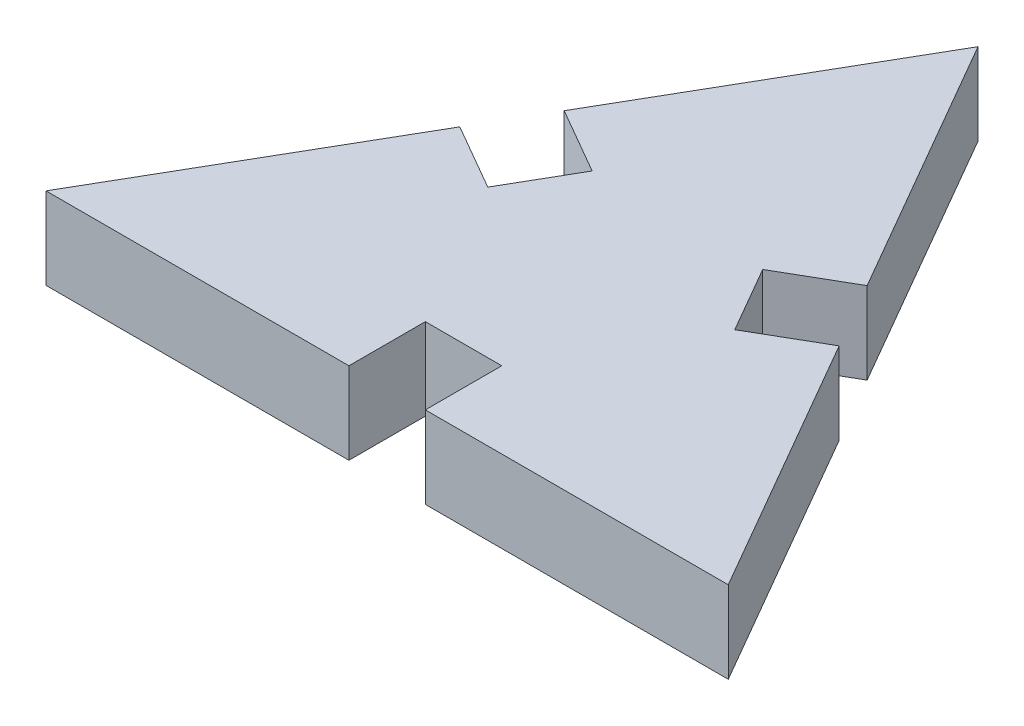
from build123d import *

# Parameters (mm, degrees)
BOSS_EXTRUDE1_DEPTH = 3
CUT_EXTRUDE1_REACH  = 5
SKETCH3_W           = 2.8
SKETCH3_H           = 2.8


with BuildPart() as part:
    # Sketch1 → Boss-Extrude1 (new body)
    with BuildSketch(Plane(origin=(0, 0, 0), x_dir=(1, 0, 0), z_dir=(0, 1, 0))):
        Polygon((0, 14.43375673), (-12.5, -7.216878365), (12.5, -7.216878365), align=None)
    extrude(amount=BOSS_EXTRUDE1_DEPTH)

    # Sketch3 → Cut-Extrude1 (cut, up to next)
    with BuildSketch(Plane(origin=(0, 3, 0), x_dir=(1, 0, 0), z_dir=(0, 1, 0)), mode=Mode.PRIVATE) as cut_extrude1_sk1:
        Polygon((6.95, 2.396003617), (4.525128869, 0.996003617), (3.125128869, 3.420874748), (5.55, 4.820874748), align=None)
    cut_extrude1_tool1 = extrude(cut_extrude1_sk1.sketch, amount=-CUT_EXTRUDE1_REACH, mode=Mode.PRIVATE) & part.part
    add(cut_extrude1_tool1.solids().sort_by_distance((5.037564, 3, -2.908439))[0], mode=Mode.SUBTRACT)
    # Sketch3 → Cut-Extrude1 (cut, up to next)
    with BuildSketch(Plane(origin=(0, 3, 0), x_dir=(1, 0, 0), z_dir=(0, 1, 0)), mode=Mode.PRIVATE) as cut_extrude1_sk2:
        Polygon((-6.95, 2.396003617), (-4.525128869, 0.996003617), (-3.125128869, 3.420874748), (-5.55, 4.820874748), align=None)
    cut_extrude1_tool2 = extrude(cut_extrude1_sk2.sketch, amount=-CUT_EXTRUDE1_REACH, mode=Mode.PRIVATE) & part.part
    add(cut_extrude1_tool2.solids().sort_by_distance((-5.037564, 3, -2.908439))[0], mode=Mode.SUBTRACT)
    # Sketch3 → Cut-Extrude1 (cut, up to next)
    with BuildSketch(Plane(origin=(0, 3, 0), x_dir=(1, 0, 0), z_dir=(0, 1, 0)), mode=Mode.PRIVATE) as cut_extrude1_sk3:
        with Locations((0, -5.816878365)):
            Rectangle(SKETCH3_W, SKETCH3_H)
    cut_extrude1_tool3 = extrude(cut_extrude1_sk3.sketch, amount=-CUT_EXTRUDE1_REACH, mode=Mode.PRIVATE) & part.part
    add(cut_extrude1_tool3.solids().sort_by_distance((0, 3, 5.816878))[0], mode=Mode.SUBTRACT)


solid = part.part
